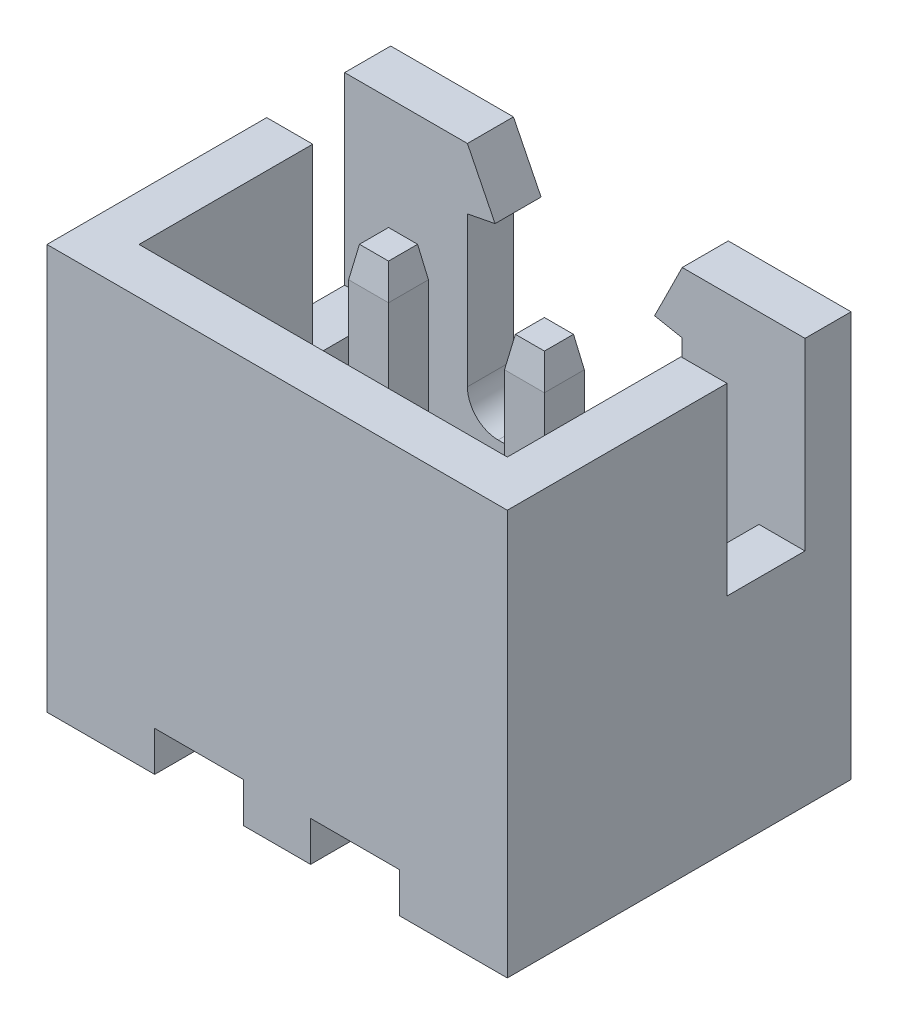
from build123d import *

# Parameters (mm, degrees)
SKETCH1_W              = 7.5
SKETCH1_H              = 5.6
EXTRUDE1_DEPTH         = 6.6
CUT_EXTRUDE1_DEPTH     = 6.6
SKETCH3_W              = 6
SKETCH3_H              = 4.1
CUT_EXTRUDE2_DEPTH     = 5.25
SKETCH5_W              = 1.27
SKETCH5_H              = 3
CUT_EXTRUDE3_DEPTH     = 8.5
CUT_EXTRUDE4_DEPTH     = 1.2
FILLET1_R              = 0.5
EXTRUDE2_DEPTH         = 6.3
EXTRUDE2_DEPTH_BACK    = 2
CHAMFER1_SIZE          = 0.5
CHAMFER1_SIZE2         = 0.08816349
CHAMFER1_PART_2_SIZE   = 0.5
CHAMFER1_PART_2_SIZE2  = 0.08816349
CHAMFER1_PART_3_SIZE   = 0.5
CHAMFER1_PART_3_SIZE2  = 0.08816349
CHAMFER1_PART_4_SIZE   = 0.5
CHAMFER1_PART_4_SIZE2  = 0.08816349
CHAMFER1_PART_5_SIZE   = 0.5
CHAMFER1_PART_5_SIZE2  = 0.08816349
CHAMFER1_PART_6_SIZE   = 0.5
CHAMFER1_PART_6_SIZE2  = 0.08816349
CHAMFER1_PART_7_SIZE   = 0.5
CHAMFER1_PART_7_SIZE2  = 0.08816349
CHAMFER1_PART_8_SIZE   = 0.5
CHAMFER1_PART_8_SIZE2  = 0.08816349
CHAMFER1_PART_9_SIZE   = 0.5
CHAMFER1_PART_9_SIZE2  = 0.08816349
CHAMFER1_PART_10_SIZE  = 0.5
CHAMFER1_PART_10_SIZE2 = 0.08816349
CHAMFER1_PART_11_SIZE  = 0.5
CHAMFER1_PART_11_SIZE2 = 0.08816349
CHAMFER1_PART_12_SIZE  = 0.5
CHAMFER1_PART_12_SIZE2 = 0.08816349
CHAMFER1_PART_13_SIZE  = 0.5
CHAMFER1_PART_13_SIZE2 = 0.08816349
CHAMFER1_PART_14_SIZE  = 0.5
CHAMFER1_PART_14_SIZE2 = 0.08816349
CHAMFER1_PART_15_SIZE  = 0.5
CHAMFER1_PART_15_SIZE2 = 0.08816349
CHAMFER1_PART_16_SIZE  = 0.5
CHAMFER1_PART_16_SIZE2 = 0.08816349


with BuildPart() as part:
    # Sketch1 → Extrude1 (new body)
    with BuildSketch(Plane(origin=(0, 0, 0), x_dir=(1, 0, 0), z_dir=(0, 1, 0))):
        Rectangle(SKETCH1_W, SKETCH1_H)
    extrude(amount=EXTRUDE1_DEPTH)

    # Sketch2 → Cut-Extrude1 (cut, through all)
    with BuildSketch(Plane.XY.offset(2.8)):
        Polygon((-1.995, 0.65), (-0.545, 0.65), (-0.545, 0), (-1.27, 0), (-1.995, 0), align=None)
        Polygon((0.545, 0.65), (1.995, 0.65), (1.995, 0), (1.27, 0), (0.545, 0), align=None)
    extrude(amount=-CUT_EXTRUDE1_DEPTH, mode=Mode.SUBTRACT)

    # Sketch3 → Cut-Extrude2 (cut)
    with BuildSketch(Plane(origin=(0, 6.6, 0), x_dir=(-1, 0, 0), z_dir=(0, 1, 0))):
        Rectangle(SKETCH3_W, SKETCH3_H)
    extrude(amount=-CUT_EXTRUDE2_DEPTH, mode=Mode.SUBTRACT)

    # Sketch5 → Cut-Extrude3 (cut, through all)
    with BuildSketch(Plane.ZY.offset(3.75)):
        with Locations((-1.415, 5.1)):
            Rectangle(SKETCH5_W, SKETCH5_H)
    extrude(amount=-CUT_EXTRUDE3_DEPTH, mode=Mode.SUBTRACT)

    # Sketch6 → Cut-Extrude4 (cut)
    with BuildSketch(Plane(origin=(0, 0, -2.8), x_dir=(-1, 0, 0), z_dir=(0, 0, -1))):
        Polygon((-1.75, 6.6), (1.75, 6.6), (1.299695014, 5.694073356), (1.75, 5.606485511), (1.75, 2.666508092), (-1.75, 2.666508092), (-1.75, 5.606485511), (-1.299695014, 5.694073356), align=None)
    extrude(amount=-CUT_EXTRUDE4_DEPTH, mode=Mode.SUBTRACT)

    # Fillet1
    fillet1_edges = [part.edges().sort_by_distance(p)[0] for p in [
        (-1.75, 2.666508092, -2.425),
        (1.75, 2.666508092, -2.425),
    ]]
    fillet(fillet1_edges, radius=FILLET1_R)

    # Sketch7 → Extrude2 (add, two sides)
    with BuildSketch(Plane(origin=(0, 0, 0), x_dir=(1, 0, 0), z_dir=(0, 1, 0))) as extrude2_sk:
        Polygon((-1.27, -0.040243902), (-0.945, -0.040243902), (-0.945, 0.609756098), (-1.595, 0.609756098), (-1.595, -0.040243902), align=None)
        Polygon((1.27, -0.040243902), (0.945, -0.040243902), (0.945, 0.609756098), (1.595, 0.609756098), (1.595, -0.040243902), align=None)
    extrude(amount=EXTRUDE2_DEPTH)
    extrude(extrude2_sk.sketch, amount=-EXTRUDE2_DEPTH_BACK)

    # Chamfer1
    chamfer1_edges = [part.edges().sort_by_distance(p)[0] for p in [
        (-1.595, -2, -0.284756098),
    ]]
    chamfer1_side = [part.faces().sort_by_distance(p)[0] for p in [
        (-1.595, -0.675, -0.284756098),
    ]]
    chamfer(chamfer1_edges, length=CHAMFER1_SIZE, length2=CHAMFER1_SIZE2, reference=chamfer1_side[0])

    # Chamfer1 part 2
    chamfer1_part_2_edges = [part.edges().sort_by_distance(p)[0] for p in [
        (-1.27, -2, 0.040243902),
    ]]
    chamfer1_part_2_side = [part.faces().sort_by_distance(p)[0] for p in [
        (-1.27, -0.675, 0.040243902),
    ]]
    chamfer(chamfer1_part_2_edges, length=CHAMFER1_PART_2_SIZE, length2=CHAMFER1_PART_2_SIZE2, reference=chamfer1_part_2_side[0])

    # Chamfer1 part 3
    chamfer1_part_3_edges = [part.edges().sort_by_distance(p)[0] for p in [
        (-0.945, -2, -0.284756098),
    ]]
    chamfer1_part_3_side = [part.faces().sort_by_distance(p)[0] for p in [
        (-0.945, -0.675, -0.284756098),
    ]]
    chamfer(chamfer1_part_3_edges, length=CHAMFER1_PART_3_SIZE, length2=CHAMFER1_PART_3_SIZE2, reference=chamfer1_part_3_side[0])

    # Chamfer1 part 4
    chamfer1_part_4_edges = [part.edges().sort_by_distance(p)[0] for p in [
        (-1.27, -2, -0.609756098),
    ]]
    chamfer1_part_4_side = [part.faces().sort_by_distance(p)[0] for p in [
        (-1.27, -0.675, -0.609756098),
    ]]
    chamfer(chamfer1_part_4_edges, length=CHAMFER1_PART_4_SIZE, length2=CHAMFER1_PART_4_SIZE2, reference=chamfer1_part_4_side[0])

    # Chamfer1 part 5
    chamfer1_part_5_edges = [part.edges().sort_by_distance(p)[0] for p in [
        (-1.27, 6.3, -0.609756098),
    ]]
    chamfer1_part_5_side = [part.faces().sort_by_distance(p)[0] for p in [
        (-1.27, 3.825, -0.609756098),
    ]]
    chamfer(chamfer1_part_5_edges, length=CHAMFER1_PART_5_SIZE, length2=CHAMFER1_PART_5_SIZE2, reference=chamfer1_part_5_side[0])

    # Chamfer1 part 6
    chamfer1_part_6_edges = [part.edges().sort_by_distance(p)[0] for p in [
        (-1.595, 6.3, -0.284756098),
    ]]
    chamfer1_part_6_side = [part.faces().sort_by_distance(p)[0] for p in [
        (-1.595, 3.825, -0.284756098),
    ]]
    chamfer(chamfer1_part_6_edges, length=CHAMFER1_PART_6_SIZE, length2=CHAMFER1_PART_6_SIZE2, reference=chamfer1_part_6_side[0])

    # Chamfer1 part 7
    chamfer1_part_7_edges = [part.edges().sort_by_distance(p)[0] for p in [
        (-1.27, 6.3, 0.040243902),
    ]]
    chamfer1_part_7_side = [part.faces().sort_by_distance(p)[0] for p in [
        (-1.27, 3.825, 0.040243902),
    ]]
    chamfer(chamfer1_part_7_edges, length=CHAMFER1_PART_7_SIZE, length2=CHAMFER1_PART_7_SIZE2, reference=chamfer1_part_7_side[0])

    # Chamfer1 part 8
    chamfer1_part_8_edges = [part.edges().sort_by_distance(p)[0] for p in [
        (-0.945, 6.3, -0.284756098),
    ]]
    chamfer1_part_8_side = [part.faces().sort_by_distance(p)[0] for p in [
        (-0.945, 3.825, -0.284756098),
    ]]
    chamfer(chamfer1_part_8_edges, length=CHAMFER1_PART_8_SIZE, length2=CHAMFER1_PART_8_SIZE2, reference=chamfer1_part_8_side[0])

    # Chamfer1 part 9
    chamfer1_part_9_edges = [part.edges().sort_by_distance(p)[0] for p in [
        (1.595, -2, -0.284756098),
    ]]
    chamfer1_part_9_side = [part.faces().sort_by_distance(p)[0] for p in [
        (1.595, -0.675, -0.284756098),
    ]]
    chamfer(chamfer1_part_9_edges, length=CHAMFER1_PART_9_SIZE, length2=CHAMFER1_PART_9_SIZE2, reference=chamfer1_part_9_side[0])

    # Chamfer1 part 10
    chamfer1_part_10_edges = [part.edges().sort_by_distance(p)[0] for p in [
        (1.27, -2, -0.609756098),
    ]]
    chamfer1_part_10_side = [part.faces().sort_by_distance(p)[0] for p in [
        (1.27, -0.675, -0.609756098),
    ]]
    chamfer(chamfer1_part_10_edges, length=CHAMFER1_PART_10_SIZE, length2=CHAMFER1_PART_10_SIZE2, reference=chamfer1_part_10_side[0])

    # Chamfer1 part 11
    chamfer1_part_11_edges = [part.edges().sort_by_distance(p)[0] for p in [
        (0.945, -2, -0.284756098),
    ]]
    chamfer1_part_11_side = [part.faces().sort_by_distance(p)[0] for p in [
        (0.945, -0.675, -0.284756098),
    ]]
    chamfer(chamfer1_part_11_edges, length=CHAMFER1_PART_11_SIZE, length2=CHAMFER1_PART_11_SIZE2, reference=chamfer1_part_11_side[0])

    # Chamfer1 part 12
    chamfer1_part_12_edges = [part.edges().sort_by_distance(p)[0] for p in [
        (1.27, -2, 0.040243902),
    ]]
    chamfer1_part_12_side = [part.faces().sort_by_distance(p)[0] for p in [
        (1.27, -0.675, 0.040243902),
    ]]
    chamfer(chamfer1_part_12_edges, length=CHAMFER1_PART_12_SIZE, length2=CHAMFER1_PART_12_SIZE2, reference=chamfer1_part_12_side[0])

    # Chamfer1 part 13
    chamfer1_part_13_edges = [part.edges().sort_by_distance(p)[0] for p in [
        (1.27, 6.3, 0.040243902),
    ]]
    chamfer1_part_13_side = [part.faces().sort_by_distance(p)[0] for p in [
        (1.27, 3.825, 0.040243902),
    ]]
    chamfer(chamfer1_part_13_edges, length=CHAMFER1_PART_13_SIZE, length2=CHAMFER1_PART_13_SIZE2, reference=chamfer1_part_13_side[0])

    # Chamfer1 part 14
    chamfer1_part_14_edges = [part.edges().sort_by_distance(p)[0] for p in [
        (1.595, 6.3, -0.284756098),
    ]]
    chamfer1_part_14_side = [part.faces().sort_by_distance(p)[0] for p in [
        (1.595, 3.825, -0.284756098),
    ]]
    chamfer(chamfer1_part_14_edges, length=CHAMFER1_PART_14_SIZE, length2=CHAMFER1_PART_14_SIZE2, reference=chamfer1_part_14_side[0])

    # Chamfer1 part 15
    chamfer1_part_15_edges = [part.edges().sort_by_distance(p)[0] for p in [
        (1.27, 6.3, -0.609756098),
    ]]
    chamfer1_part_15_side = [part.faces().sort_by_distance(p)[0] for p in [
        (1.27, 3.825, -0.609756098),
    ]]
    chamfer(chamfer1_part_15_edges, length=CHAMFER1_PART_15_SIZE, length2=CHAMFER1_PART_15_SIZE2, reference=chamfer1_part_15_side[0])

    # Chamfer1 part 16
    chamfer1_part_16_edges = [part.edges().sort_by_distance(p)[0] for p in [
        (0.945, 6.3, -0.284756098),
    ]]
    chamfer1_part_16_side = [part.faces().sort_by_distance(p)[0] for p in [
        (0.945, 3.825, -0.284756098),
    ]]
    chamfer(chamfer1_part_16_edges, length=CHAMFER1_PART_16_SIZE, length2=CHAMFER1_PART_16_SIZE2, reference=chamfer1_part_16_side[0])


solid = part.part
